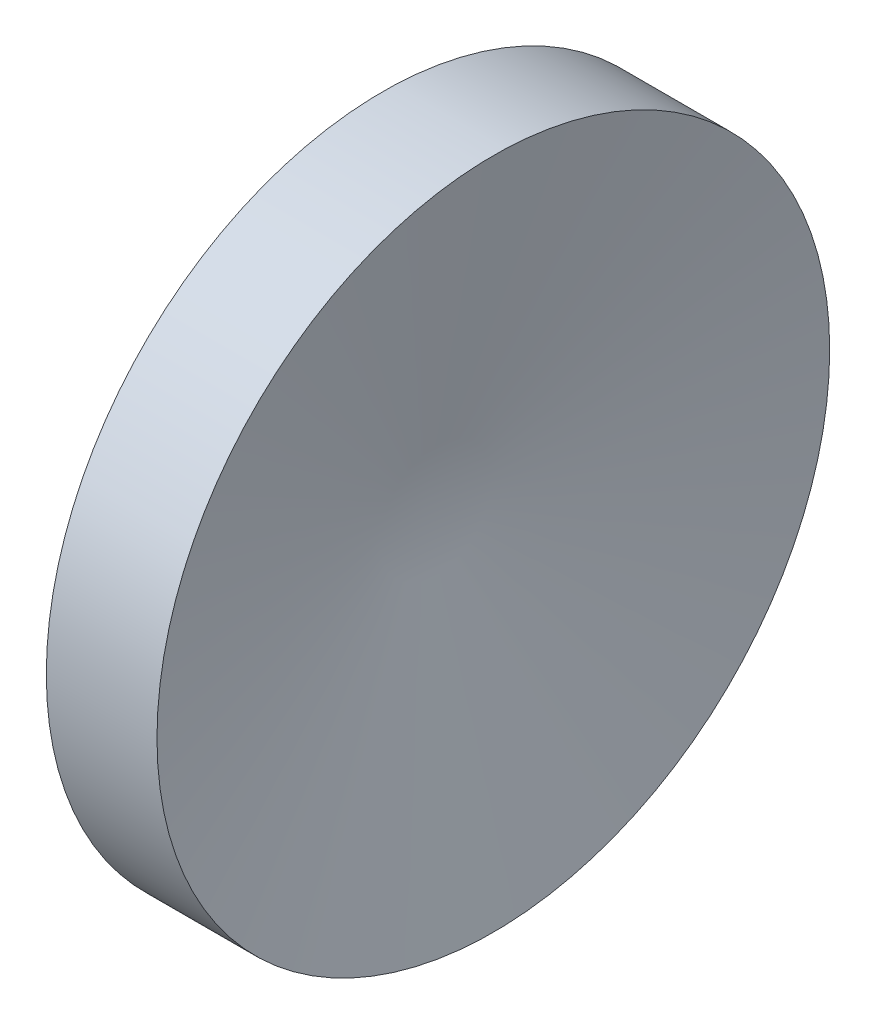
from build123d import *


with BuildPart() as part:
    # Croquis1 → Revolución1 (revolve)
    with BuildSketch(Plane.XY):
        Polygon((0, -30.593654224), (0, 37.234805652), (22.318448693, 37.234805652), (8.425872574, -30.593654224), align=None)
    revolve(axis=Axis((8.425872574, -30.593654224, 0), (-1, 0, 0)))


solid = part.part
